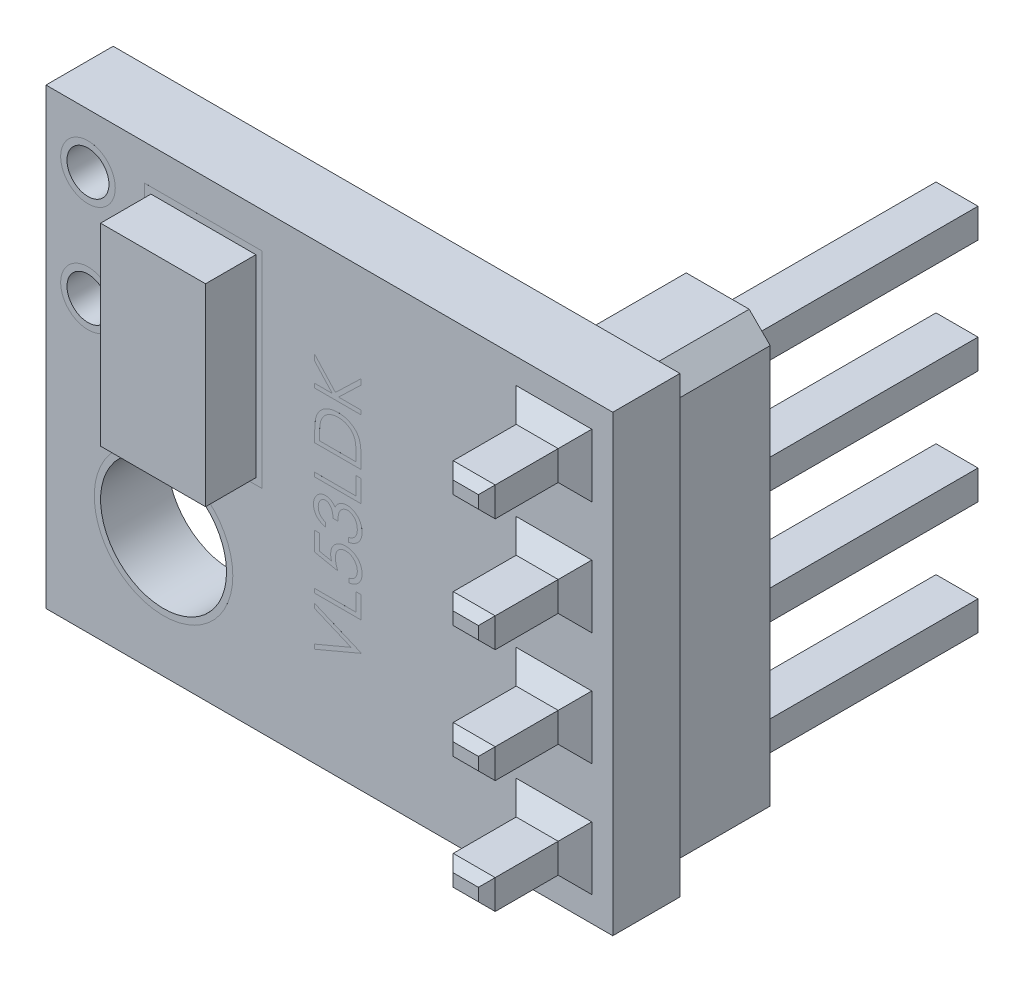
from build123d import *

# Parameters (mm, degrees)
SKETCH1_W                = 13.5
SKETCH1_H                = 10.8
BOSS_EXTRUDE1_DEPTH      = 0.8
SKETCH2_W                = 2.5
SKETCH2_H                = 4.6
BOSS_EXTRUDE2_DEPTH      = 1.2
SKETCH3_R                = 1.5
CUT_EXTRUDE1_DEPTH       = 3
CUT_EXTRUDE1_DEPTH_BACK  = 1.8
SKETCH6_R                = 0.5
CUT_EXTRUDE2_DEPTH       = 3
CUT_EXTRUDE2_DEPTH_BACK  = 1.8
SKETCH7_R                = 0.65
SKETCH7_R_2              = 0.5
SKETCH7_R_3              = 1.65
SKETCH7_R_4              = 1.5
BOSS_EXTRUDE6_DEPTH      = 0.0001
SKETCH8_W                = 2.8
SKETCH8_H                = 4.9
SKETCH8_W_2              = 2.5
SKETCH8_H_2              = 4.6
BOSS_EXTRUDE7_DEPTH      = 0.0001
SKETCH4_W                = 2.5
SKETCH4_H                = 10.5
BOSS_EXTRUDE3_DEPTH      = 2.3
SKETCH5_W                = 1
SKETCH5_H                = 0.7
BOSS_EXTRUDE4_DEPTH      = 5.9
BOSS_EXTRUDE4_DEPTH_BACK = 6
CHAMFER3_SIZE            = 0.2
CHAMFER1_SIZE            = 0.4
CHAMFER2_SIZE            = 0.5


with BuildPart() as part:
    # Sketch1 → Boss-Extrude1 (new body, symmetric)
    with BuildSketch(Plane.XY):
        Rectangle(SKETCH1_W, SKETCH1_H)
    extrude(amount=BOSS_EXTRUDE1_DEPTH, both=True)

    # Sketch2 → Boss-Extrude2 (add)
    with BuildSketch(Plane.XY.offset(0.8)):
        with Locations((-3, 2.1)):
            Rectangle(SKETCH2_W, SKETCH2_H)
    extrude(amount=BOSS_EXTRUDE2_DEPTH)

    # Sketch3 → Cut-Extrude1 (cut, two sides)
    with BuildSketch(Plane.XY) as cut_extrude1_sk:
        with Locations((-3.95, -2.5)):
            Circle(SKETCH3_R)
    extrude(amount=CUT_EXTRUDE1_DEPTH, mode=Mode.SUBTRACT)
    extrude(cut_extrude1_sk.sketch, amount=-CUT_EXTRUDE1_DEPTH_BACK, mode=Mode.SUBTRACT)

    # Sketch6 → Cut-Extrude2 (cut, two sides)
    with BuildSketch(Plane.XY) as cut_extrude2_sk:
        with Locations((-5.75, 4.1)):
            Circle(SKETCH6_R)
        with Locations((-5.75, 1.5)):
            Circle(SKETCH6_R)
    extrude(amount=CUT_EXTRUDE2_DEPTH, mode=Mode.SUBTRACT)
    extrude(cut_extrude2_sk.sketch, amount=-CUT_EXTRUDE2_DEPTH_BACK, mode=Mode.SUBTRACT)

    # Sketch7 → Boss-Extrude6 (add)
    with BuildSketch(Plane.XY.offset(0.8)):
        with Locations((-5.75, 1.5)):
            Circle(SKETCH7_R)
        with Locations((-5.75, 1.5)):
            Circle(SKETCH7_R_2, mode=Mode.SUBTRACT)
        with Locations((-5.75, 4.1)):
            Circle(SKETCH7_R)
        with Locations((-5.75, 4.1)):
            Circle(SKETCH7_R_2, mode=Mode.SUBTRACT)
        with Locations((-3.95, -2.5)):
            Circle(SKETCH7_R_3)
        with Locations((-3.95, -2.5)):
            Circle(SKETCH7_R_4, mode=Mode.SUBTRACT)
    boss_extrude6 = extrude(amount=BOSS_EXTRUDE6_DEPTH)

    # Sketch8 → Boss-Extrude7 (add)
    with BuildSketch(Plane.XY.offset(0.8)):
        with Locations((-3, 2.1)):
            Rectangle(SKETCH8_W, SKETCH8_H)
        with Locations((-3, 2.1)):
            Rectangle(SKETCH8_W_2, SKETCH8_H_2, mode=Mode.SUBTRACT)
        Polygon((-0.35, -3.039102564), (-0.35, -2.933333333), (0.516866987, -2.566666667), (-0.35, -2.2), (-0.35, -2.094230769), (0.75, -2.559615385), (0.75, -2.573717949), align=None)
        Polygon((-0.35, -1.882692308), (-0.35, -1.783974359), (0.637179487, -1.783974359), (0.637179487, -1.360897436), (0.75, -1.360897436), (0.75, -1.882692308), align=None)
        with BuildLine():
            Line((-0.35, -0.58525641), (-0.237179487, -0.58525641))
            Line((-0.237179487, -0.58525641), (-0.237179487, -0.959415064))
            Line((-0.237179487, -0.959415064), (0.052143429, -1.018689904))
            add(Edge.make_bspline(
                [(0.052143429, -1.018689904), (0.048928201, -1.007043772), (0.042699205, -0.984481233), (0.035783106, -0.951179563), (0.031613966, -0.91956487), (0.031044697, -0.899049754), (0.030769231, -0.889122596)],
                knots=[0, 0, 0, 0, 3.6238e-05, 7.0205e-05, 0.000101964, 0.000131741, 0.000131741, 0.000131741, 0.000131741], degree=3))
            add(Edge.make_bspline(
                [(0.030769231, -0.889122596), (0.031026316, -0.87683688), (0.03153181, -0.852680093), (0.03667389, -0.81739074), (0.044121774, -0.783533578), (0.055596649, -0.751608503), (0.069609518, -0.72111043), (0.087259033, -0.692563126), (0.107864798, -0.665565929), (0.13132069, -0.640305428), (0.157403456, -0.617496772), (0.185563621, -0.597676801), (0.215186682, -0.580377643), (0.246966944, -0.566885852), (0.280305019, -0.555875235), (0.315585743, -0.548614807), (0.3524959, -0.543765155), (0.377734772, -0.543224445), (0.390604968, -0.542948718)],
                knots=[0, 0, 0, 0, 3.6831e-05, 7.2419e-05, 0.000106789, 0.000140659, 0.000173979, 0.000207311, 0.000241115, 0.000275727, 0.000310552, 0.000344852, 0.000378907, 0.000413251, 0.000448232, 0.000484061, 0.000521149, 0.000559742, 0.000559742, 0.000559742, 0.000559742], degree=3))
            add(Edge.make_bspline(
                [(0.390604968, -0.542948718), (0.399569038, -0.54315793), (0.417376037, -0.543573526), (0.443822179, -0.545682322), (0.469704586, -0.549758102), (0.494975807, -0.555163854), (0.519659512, -0.562380264), (0.543893902, -0.570821168), (0.567413613, -0.581312654), (0.590322523, -0.592943637), (0.612358445, -0.605822759), (0.63299303, -0.620305045), (0.652697163, -0.635352975), (0.67088566, -0.651795617), (0.687629074, -0.669446026), (0.703010177, -0.688205995), (0.717305016, -0.707905366), (0.729929114, -0.728854405), (0.741546095, -0.750584832), (0.751076336, -0.773410861), (0.759596791, -0.796812791), (0.766388356, -0.821127467), (0.771710016, -0.846299808), (0.775324491, -0.872371309), (0.777957085, -0.899205234), (0.778121883, -0.917394524), (0.778205128, -0.926582532)],
                knots=[0, 0, 0, 0, 2.6897e-05, 5.3431e-05, 7.9516e-05, 0.000105448, 0.000130904, 0.000156621, 0.000182373, 0.000208094, 0.000233678, 0.000258861, 0.000283676, 0.000308015, 0.00033233, 0.000356594, 0.000380749, 0.000405276, 0.000429917, 0.000454597, 0.00047941, 0.000504593, 0.000530264, 0.000556534, 0.000583526, 0.000611078, 0.000611078, 0.000611078, 0.000611078], degree=3))
            add(Edge.make_bspline(
                [(0.778205128, -0.926582532), (0.777987424, -0.937542709), (0.777559116, -0.959105563), (0.773098773, -0.990701726), (0.766668289, -1.021083196), (0.757141178, -1.050119764), (0.744666105, -1.07769033), (0.729843832, -1.104189698), (0.712198142, -1.129289422), (0.691890434, -1.1528179), (0.669576543, -1.174445788), (0.645593481, -1.194058116), (0.619910704, -1.211300973), (0.592611726, -1.226236908), (0.563744968, -1.238960963), (0.533221484, -1.248961033), (0.501195525, -1.257031079), (0.479147313, -1.260445338), (0.467948718, -1.262179487)],
                knots=[0, 0, 0, 0, 3.2859e-05, 6.4646e-05, 9.555e-05, 0.000125932, 0.000156113, 0.000186206, 0.000216894, 0.000247989, 0.000279311, 0.000310009, 0.000340811, 0.000371973, 0.000403252, 0.000435305, 0.000468227, 0.000502207, 0.000502207, 0.000502207, 0.000502207], degree=3))
            Line((0.467948718, -1.262179487), (0.467948718, -1.163461538))
            add(Edge.make_bspline(
                [(0.467948718, -1.163461538), (0.478439552, -1.161034083), (0.498603518, -1.156368378), (0.526915977, -1.146100635), (0.552154748, -1.133668446), (0.574474144, -1.118540637), (0.594282718, -1.10100557), (0.611747892, -1.080621961), (0.627523714, -1.057899393), (0.640696215, -1.032636359), (0.651792271, -1.005932111), (0.659710781, -0.978141995), (0.664504026, -0.949665963), (0.665089981, -0.930493712), (0.665384615, -0.920853365)],
                knots=[0, 0, 0, 0, 3.228e-05, 6.2044e-05, 9.0129e-05, 0.00011647, 0.000142693, 0.000169247, 0.000196813, 0.000225498, 0.000254551, 0.000283427, 0.000312009, 0.000340916, 0.000340916, 0.000340916, 0.000340916], degree=3))
            add(Edge.make_bspline(
                [(0.665384615, -0.920853365), (0.665124498, -0.911438653), (0.664612325, -0.892901007), (0.66073388, -0.865605972), (0.654603728, -0.839330664), (0.646015737, -0.81402844), (0.634654327, -0.789823631), (0.620697491, -0.766750459), (0.604493438, -0.744480228), (0.585972796, -0.723599056), (0.565551447, -0.704479094), (0.543716297, -0.68758405), (0.520422273, -0.673511375), (0.49607361, -0.661652065), (0.470403195, -0.652646748), (0.4435314, -0.646222438), (0.415391834, -0.642450048), (0.396198622, -0.641931106), (0.386418269, -0.641666667)],
                knots=[0, 0, 0, 0, 2.8236e-05, 5.5597e-05, 8.2535e-05, 0.000109085, 0.000135602, 0.000162584, 0.000189866, 0.00021812, 0.000246182, 0.000273684, 0.00030078, 0.000327686, 0.000354796, 0.000382214, 0.000410448, 0.000439785, 0.000439785, 0.000439785, 0.000439785], degree=3))
            add(Edge.make_bspline(
                [(0.386418269, -0.641666667), (0.377593419, -0.641867329), (0.360392872, -0.642258442), (0.33513981, -0.645644274), (0.311207336, -0.651300255), (0.288491314, -0.659353222), (0.267064375, -0.669403582), (0.246973736, -0.682022114), (0.228030494, -0.696671509), (0.210722136, -0.713774347), (0.194722172, -0.732378693), (0.181132083, -0.752962404), (0.169574818, -0.77497597), (0.160105682, -0.798460186), (0.152562791, -0.823443979), (0.147349795, -0.849940805), (0.144230418, -0.877956703), (0.143807259, -0.897120477), (0.143589744, -0.906971154)],
                knots=[0, 0, 0, 0, 2.6465e-05, 5.1584e-05, 7.6276e-05, 0.000100111, 0.000123766, 0.000147124, 0.000171146, 0.000195455, 0.000220001, 0.000244631, 0.000269272, 0.000294478, 0.00032048, 0.000347446, 0.000375382, 0.000404929, 0.000404929, 0.000404929, 0.000404929], degree=3))
            add(Edge.make_bspline(
                [(0.143589744, -0.906971154), (0.143772215, -0.915497389), (0.144148972, -0.9331019), (0.146923014, -0.960106217), (0.151398221, -0.988483616), (0.157553899, -1.018125314), (0.16560938, -1.049120331), (0.175262509, -1.081403257), (0.186803709, -1.11504197), (0.195519547, -1.13770754), (0.2, -1.149358974)],
                knots=[0, 0, 0, 0, 2.5576e-05, 5.2808e-05, 8.1355e-05, 0.000111736, 0.000143589, 0.000177401, 0.0002128, 0.000250248, 0.000250248, 0.000250248, 0.000250248], degree=3))
            Line((0.2, -1.149358974), (-0.35, -1.036538462))
            Line((-0.35, -1.036538462), (-0.35, -0.58525641))
        make_face()
        with BuildLine():
            Line((-0.096153846, -0.289102564), (-0.096153846, -0.387820513))
            add(Edge.make_bspline(
                [(-0.096153846, -0.387820513), (-0.107226913, -0.385146083), (-0.128873852, -0.37991779), (-0.159801848, -0.369012839), (-0.18906924, -0.357133073), (-0.216128006, -0.342867926), (-0.241521947, -0.327308031), (-0.264675101, -0.30948089), (-0.286176318, -0.290208978), (-0.305257622, -0.268892565), (-0.322536336, -0.246537843), (-0.337268497, -0.222829819), (-0.349941803, -0.198245481), (-0.360382447, -0.172614497), (-0.368247611, -0.145860557), (-0.373954036, -0.118225533), (-0.377659815, -0.089637004), (-0.378021483, -0.070230618), (-0.378205128, -0.060376603)],
                knots=[0, 0, 0, 0, 3.4152e-05, 6.6764e-05, 9.8274e-05, 0.000128827, 0.000158421, 0.000187508, 0.000216368, 0.000244916, 0.000273211, 0.000301029, 0.000328525, 0.000356104, 0.000383922, 0.000412055, 0.000440699, 0.000470246, 0.000470246, 0.000470246, 0.000470246], degree=3))
            add(Edge.make_bspline(
                [(-0.378205128, -0.060376603), (-0.377771656, -0.046019169), (-0.376914166, -0.01761748), (-0.369083915, 0.024108049), (-0.356693159, 0.064345049), (-0.339572845, 0.102653098), (-0.318456832, 0.138236034), (-0.293325058, 0.169895979), (-0.26466242, 0.197203796), (-0.233003614, 0.220113458), (-0.199169025, 0.238051315), (-0.164346119, 0.251278461), (-0.128617499, 0.259330989), (-0.104493783, 0.260374593), (-0.092407853, 0.260897436)],
                knots=[0, 0, 0, 0, 4.3037e-05, 8.5135e-05, 0.000126884, 0.000169103, 0.00021071, 0.000250698, 0.000289974, 0.000329115, 0.00036756, 0.000404518, 0.000440608, 0.000476842, 0.000476842, 0.000476842, 0.000476842], degree=3))
            add(Edge.make_bspline(
                [(-0.092407853, 0.260897436), (-0.080777146, 0.260531736), (-0.058017657, 0.259816118), (-0.024790901, 0.25373981), (0.006525031, 0.243514128), (0.036061967, 0.229349345), (0.063632631, 0.211013429), (0.089299054, 0.18880201), (0.113175075, 0.162558316), (0.126852624, 0.14267065), (0.133894231, 0.132431891)],
                knots=[0, 0, 0, 0, 3.4872e-05, 6.8239e-05, 0.000100921, 0.000133444, 0.000166202, 0.00019995, 0.000235049, 0.000272295, 0.000272295, 0.000272295, 0.000272295], degree=3))
            add(Edge.make_bspline(
                [(0.133894231, 0.132431891), (0.13952403, 0.144148215), (0.150696368, 0.167399261), (0.172955169, 0.198771708), (0.198024105, 0.227685518), (0.217805987, 0.243620678), (0.227764423, 0.251642628)],
                knots=[0, 0, 0, 0, 3.8928e-05, 7.7253e-05, 0.000115023, 0.000153312, 0.000153312, 0.000153312, 0.000153312], degree=3))
            add(Edge.make_bspline(
                [(0.227764423, 0.251642628), (0.235011145, 0.256935622), (0.249385919, 0.267434932), (0.272497367, 0.280394671), (0.295864978, 0.292151821), (0.320115077, 0.301313319), (0.344966595, 0.308407962), (0.370462206, 0.313479287), (0.396622727, 0.316629731), (0.414320935, 0.317080905), (0.423217147, 0.317307692)],
                knots=[0, 0, 0, 0, 2.6897e-05, 5.3354e-05, 7.9371e-05, 0.000105317, 0.000130984, 0.000156826, 0.000183229, 0.000209914, 0.000209914, 0.000209914, 0.000209914], degree=3))
            add(Edge.make_bspline(
                [(0.423217147, 0.317307692), (0.438620124, 0.316743621), (0.46935359, 0.315618133), (0.514761112, 0.305560929), (0.559141665, 0.289963442), (0.601611537, 0.267838187), (0.641309643, 0.240751743), (0.677091108, 0.208883351), (0.707365284, 0.171777414), (0.732966609, 0.130778714), (0.753240829, 0.086169329), (0.76785375, 0.038650918), (0.776618568, -0.011501525), (0.777670254, -0.045798274), (0.778205128, -0.063241186)],
                knots=[0, 0, 0, 0, 4.6157e-05, 9.2097e-05, 0.000138862, 0.000186955, 0.000235301, 0.000282733, 0.00033016, 0.000378463, 0.000427374, 0.000476721, 0.000527257, 0.000579559, 0.000579559, 0.000579559, 0.000579559], degree=3))
            add(Edge.make_bspline(
                [(0.778205128, -0.063241186), (0.777929881, -0.075000797), (0.777388287, -0.098139791), (0.773751764, -0.132169719), (0.766929382, -0.164584042), (0.758349292, -0.195697517), (0.746486357, -0.225040566), (0.73234354, -0.253035261), (0.715558168, -0.279558892), (0.696102012, -0.304453942), (0.674323755, -0.327693816), (0.6498616, -0.348686439), (0.623172094, -0.36766407), (0.594015161, -0.384506129), (0.562472466, -0.399283498), (0.528417611, -0.411678166), (0.492114605, -0.422500242), (0.466822729, -0.427541614), (0.453846154, -0.430128205)],
                knots=[0, 0, 0, 0, 3.5281e-05, 6.9422e-05, 0.000102481, 0.000134565, 0.000166113, 0.000197254, 0.000228553, 0.000260113, 0.000291912, 0.000323939, 0.00035665, 0.000390023, 0.00042482, 0.000461005, 0.000498658, 0.000538334, 0.000538334, 0.000538334, 0.000538334], degree=3))
            Line((0.453846154, -0.430128205), (0.453846154, -0.331410256))
            add(Edge.make_bspline(
                [(0.453846154, -0.331410256), (0.462315844, -0.328838365), (0.478790126, -0.323835812), (0.502499937, -0.315320461), (0.524235325, -0.305619005), (0.544155735, -0.295211572), (0.562457347, -0.284281203), (0.57865622, -0.272050798), (0.593463855, -0.25942621), (0.601806447, -0.249909841), (0.605889423, -0.245252404)],
                knots=[0, 0, 0, 0, 2.6553e-05, 5.1648e-05, 7.5521e-05, 9.7894e-05, 0.000119057, 0.000139373, 0.000158734, 0.000177293, 0.000177293, 0.000177293, 0.000177293], degree=3))
            add(Edge.make_bspline(
                [(0.605889423, -0.245252404), (0.610635799, -0.239092792), (0.620113899, -0.226792581), (0.632243796, -0.206761461), (0.642626697, -0.185621153), (0.651066355, -0.16319536), (0.657401467, -0.139481075), (0.661961182, -0.114574493), (0.664971302, -0.088434748), (0.665244835, -0.070594883), (0.665384615, -0.061478365)],
                knots=[0, 0, 0, 0, 2.3314e-05, 4.6555e-05, 7.0108e-05, 9.3887e-05, 0.000118315, 0.000143642, 0.000169801, 0.000197138, 0.000197138, 0.000197138, 0.000197138], degree=3))
            add(Edge.make_bspline(
                [(0.665384615, -0.061478365), (0.665191045, -0.051184407), (0.664812535, -0.031055461), (0.661331599, -0.001683934), (0.65626204, 0.026258407), (0.648432246, 0.052461326), (0.638758264, 0.077268057), (0.626611622, 0.100330861), (0.612360424, 0.121952495), (0.596162403, 0.141856022), (0.578429933, 0.159753182), (0.559882968, 0.175511314), (0.540599707, 0.188907636), (0.52047344, 0.199713904), (0.499587511, 0.208246934), (0.477883308, 0.21405594), (0.455538453, 0.218094987), (0.440349348, 0.218423923), (0.432692308, 0.218589744)],
                knots=[0, 0, 0, 0, 3.0869e-05, 6.0362e-05, 8.8625e-05, 0.000115958, 0.000142269, 0.000168388, 0.000193995, 0.00021984, 0.000245238, 0.000269474, 0.000292762, 0.000315536, 0.000337877, 0.000360277, 0.000382845, 0.000405788, 0.000405788, 0.000405788, 0.000405788], degree=3))
            add(Edge.make_bspline(
                [(0.432692308, 0.218589744), (0.422443685, 0.21810778), (0.401997436, 0.21714625), (0.371904951, 0.209835855), (0.342900597, 0.19770305), (0.31536003, 0.181050544), (0.29014639, 0.160283607), (0.267488959, 0.136384076), (0.248810914, 0.10870176), (0.235894185, 0.083242464), (0.227082989, 0.060687109), (0.221213607, 0.04138527), (0.216243634, 0.019776009), (0.211619767, -0.003879116), (0.207684489, -0.029758416), (0.204402775, -0.057833696), (0.201776905, -0.08811065), (0.200604275, -0.10907073), (0.2, -0.119871795)],
                knots=[0, 0, 0, 0, 3.0725e-05, 6.1297e-05, 9.2316e-05, 0.00012474, 0.000157468, 0.000190052, 0.000223179, 0.000257276, 0.000275485, 0.000295768, 0.000317735, 0.000341979, 0.000368063, 0.000396243, 0.000426766, 0.000459219, 0.000459219, 0.000459219, 0.000459219], degree=3))
            Line((0.2, -0.119871795), (0.087179487, -0.119871795))
            add(Edge.make_bspline(
                [(0.087179487, -0.119871795), (0.086915262, -0.106267775), (0.08639789, -0.07963016), (0.08139606, -0.040616388), (0.073366156, -0.003468245), (0.061892809, 0.031280255), (0.048378592, 0.062891109), (0.032763287, 0.090426226), (0.015089284, 0.113160731), (-0.00430503, 0.13133214), (-0.024992613, 0.145143688), (-0.046686533, 0.155076553), (-0.069472793, 0.16099655), (-0.0850292, 0.161783786), (-0.092848558, 0.162179487)],
                knots=[0, 0, 0, 0, 4.0794e-05, 7.9878e-05, 0.000117785, 0.000154647, 0.000189483, 0.000220778, 0.000249343, 0.000275536, 0.000300165, 0.000323635, 0.00034683, 0.000370271, 0.000370271, 0.000370271, 0.000370271], degree=3))
            add(Edge.make_bspline(
                [(-0.092848558, 0.162179487), (-0.098593948, 0.162052094), (-0.110024129, 0.161798652), (-0.126775759, 0.158475381), (-0.143014557, 0.153711121), (-0.158555373, 0.146793988), (-0.173430013, 0.137831772), (-0.187801651, 0.127021578), (-0.201484585, 0.114055313), (-0.214549407, 0.099532955), (-0.22643478, 0.083451967), (-0.236836447, 0.066187463), (-0.245660272, 0.047809449), (-0.252960671, 0.028435648), (-0.258446228, 0.007975777), (-0.262386526, -0.013466498), (-0.26484966, -0.035934155), (-0.265204323, -0.0512624), (-0.265384615, -0.059054487)],
                knots=[0, 0, 0, 0, 1.721e-05, 3.4239e-05, 5.1039e-05, 6.7909e-05, 8.5103e-05, 0.00010304, 0.000121748, 0.000141566, 0.000161575, 0.000181641, 0.000201943, 0.000222653, 0.000243661, 0.0002654, 0.000288006, 0.00031138, 0.00031138, 0.00031138, 0.00031138], degree=3))
            add(Edge.make_bspline(
                [(-0.265384615, -0.059054487), (-0.26494733, -0.071579297), (-0.26409321, -0.096043164), (-0.256612263, -0.131310709), (-0.244676294, -0.164096786), (-0.230428774, -0.18915751), (-0.216364352, -0.207663461), (-0.204081316, -0.220887642), (-0.190431, -0.233874088), (-0.174572654, -0.245768444), (-0.157580234, -0.257797408), (-0.138589934, -0.268748556), (-0.118097124, -0.279390173), (-0.103609925, -0.285802403), (-0.096153846, -0.289102564)],
                knots=[0, 0, 0, 0, 3.7538e-05, 7.3321e-05, 0.000107622, 0.000141869, 0.000159321, 0.000177256, 0.000195964, 0.000215754, 0.000236659, 0.000258389, 0.00028145, 0.000305906, 0.000305906, 0.000305906, 0.000305906], degree=3))
        make_face()
        Polygon((-0.35, 0.51474359), (-0.35, 0.613461538), (0.637179487, 0.613461538), (0.637179487, 1.036538462), (0.75, 1.036538462), (0.75, 0.51474359), align=None)
        with BuildLine():
            Line((0.75, 1.219871795), (-0.35, 1.219871795))
            Line((-0.35, 1.219871795), (-0.35, 1.441987179))
            add(Edge.make_bspline(
                [(-0.35, 1.441987179), (-0.349860907, 1.461306004), (-0.349592179, 1.498629873), (-0.347888313, 1.552565214), (-0.344874167, 1.602468682), (-0.340483744, 1.648176152), (-0.335092791, 1.689813105), (-0.328335521, 1.727262953), (-0.320356381, 1.760719341), (-0.313553526, 1.781295451), (-0.310336538, 1.791025641)],
                knots=[0, 0, 0, 0, 5.7956e-05, 0.000111972, 0.000161867, 0.000207912, 0.000249702, 0.00028778, 0.000322038, 0.000352771, 0.000352771, 0.000352771, 0.000352771], degree=3))
            add(Edge.make_bspline(
                [(-0.310336538, 1.791025641), (-0.305488398, 1.803753705), (-0.295902058, 1.828921204), (-0.27779101, 1.864735374), (-0.257354692, 1.898565306), (-0.234122806, 1.930141277), (-0.208398723, 1.959542516), (-0.180366215, 1.987102717), (-0.149402551, 2.012142383), (-0.116058867, 2.035051507), (-0.08076239, 2.05571263), (-0.043570924, 2.073670288), (-0.004675919, 2.088584499), (0.03581516, 2.1009652), (0.077991155, 2.110722665), (0.12190123, 2.117379842), (0.167371832, 2.121770725), (0.198226663, 2.122211998), (0.213882212, 2.122435897)],
                knots=[0, 0, 0, 0, 4.0837e-05, 8.0747e-05, 0.000120201, 0.000159293, 0.000198181, 0.000237293, 0.000277076, 0.000317478, 0.000358558, 0.000399656, 0.000441232, 0.000483402, 0.000526592, 0.000570971, 0.000616556, 0.00066351, 0.00066351, 0.00066351, 0.00066351], degree=3))
            add(Edge.make_bspline(
                [(0.213882212, 2.122435897), (0.227478601, 2.122238222), (0.254271706, 2.121848681), (0.293758846, 2.118350898), (0.332074533, 2.113266904), (0.369036348, 2.1053959), (0.404967988, 2.095840719), (0.439487007, 2.083595229), (0.472908199, 2.069565513), (0.504786486, 2.05321219), (0.534968772, 2.035234543), (0.563442294, 2.016061922), (0.589575215, 1.995259507), (0.614052335, 1.973442985), (0.636219777, 1.950086256), (0.656481622, 1.925473683), (0.674498644, 1.899509615), (0.690553962, 1.872033328), (0.704911789, 1.842677869), (0.71688794, 1.81051986), (0.727260509, 1.775711626), (0.735511888, 1.738054666), (0.742166684, 1.697683291), (0.746597473, 1.654485508), (0.749602385, 1.608542957), (0.749864888, 1.576995079), (0.75, 1.560757212)],
                knots=[0, 0, 0, 0, 4.078e-05, 8.0361e-05, 0.000118848, 0.000156662, 0.000193652, 0.000230309, 0.000266447, 0.000302319, 0.000337691, 0.000371794, 0.00040521, 0.00043782, 0.000470083, 0.000501711, 0.000533374, 0.000564779, 0.000597105, 0.000631277, 0.0006676, 0.000705985, 0.000746848, 0.000790284, 0.000836207, 0.000884912, 0.000884912, 0.000884912, 0.000884912], degree=3))
            Line((0.75, 1.560757212), (0.75, 1.219871795))
        make_face()
        with BuildLine():
            Line((0.637179487, 1.318589744), (0.637179487, 1.444851763))
            add(Edge.make_bspline(
                [(0.637179487, 1.444851763), (0.637101514, 1.462994965), (0.636951543, 1.497890987), (0.635635565, 1.548069215), (0.633485242, 1.593917025), (0.630475932, 1.635440928), (0.626494367, 1.672617479), (0.622055112, 1.705524372), (0.616524484, 1.734053739), (0.611511326, 1.751317276), (0.609194712, 1.759294872)],
                knots=[0, 0, 0, 0, 5.4429e-05, 0.000104687, 0.000150573, 0.000192114, 0.000229564, 0.000262721, 0.000291718, 0.00031663, 0.00031663, 0.00031663, 0.00031663], degree=3))
            add(Edge.make_bspline(
                [(0.609194712, 1.759294872), (0.605658508, 1.769335787), (0.598670564, 1.789177789), (0.585923861, 1.817740401), (0.570824959, 1.844378372), (0.554041259, 1.869555605), (0.534981567, 1.892916171), (0.514057454, 1.914732327), (0.491173323, 1.934977366), (0.466366282, 1.953339457), (0.439905334, 1.969971286), (0.411743679, 1.984249014), (0.382277228, 1.996683044), (0.351267434, 2.006528545), (0.318941582, 2.01429129), (0.285132049, 2.019732541), (0.249868751, 2.023110552), (0.225862414, 2.023513276), (0.213661859, 2.023717949)],
                knots=[0, 0, 0, 0, 3.1929e-05, 6.3096e-05, 9.368e-05, 0.000123688, 0.000153766, 0.000184, 0.000214285, 0.000245311, 0.000276493, 0.00030793, 0.000339932, 0.000372336, 0.000405419, 0.00043958, 0.000474991, 0.000511586, 0.000511586, 0.000511586, 0.000511586], degree=3))
            add(Edge.make_bspline(
                [(0.213661859, 2.023717949), (0.200797051, 2.02355663), (0.175524022, 2.023239717), (0.138441232, 2.019256363), (0.102775884, 2.013435302), (0.068525594, 2.005017573), (0.035623541, 1.994290725), (0.004251695, 1.980903837), (-0.025921264, 1.965608614), (-0.054198922, 1.947410423), (-0.080942471, 1.927479808), (-0.105442587, 1.905361046), (-0.127755081, 1.881405548), (-0.148227437, 1.855874595), (-0.16603602, 1.82804865), (-0.18196612, 1.798583204), (-0.1954854, 1.767045993), (-0.2026759, 1.74510486), (-0.206330128, 1.733954327)],
                knots=[0, 0, 0, 0, 3.8577e-05, 7.5786e-05, 0.000111758, 0.000146924, 0.000181486, 0.000215455, 0.00024916, 0.000282842, 0.000316203, 0.000349124, 0.000381707, 0.000414332, 0.000447153, 0.000480673, 0.000514728, 0.000549919, 0.000549919, 0.000549919, 0.000549919], degree=3))
            add(Edge.make_bspline(
                [(-0.206330128, 1.733954327), (-0.208881006, 1.724729681), (-0.214304871, 1.705115553), (-0.220221416, 1.673108864), (-0.225439973, 1.63708696), (-0.229858214, 1.596889911), (-0.233028515, 1.552563538), (-0.235408071, 1.50407375), (-0.237013013, 1.451399589), (-0.237122606, 1.414885078), (-0.237179487, 1.395933494)],
                knots=[0, 0, 0, 0, 2.8701e-05, 6.1026e-05, 9.7549e-05, 0.000137894, 0.000182308, 0.000230846, 0.000283533, 0.000340386, 0.000340386, 0.000340386, 0.000340386], degree=3))
            Line((-0.237179487, 1.395933494), (-0.237179487, 1.318589744))
            Line((-0.237179487, 1.318589744), (0.637179487, 1.318589744))
        make_face(mode=Mode.SUBTRACT)
        Polygon((-0.35, 2.348076923), (-0.35, 2.446794872), (0.068890224, 2.446794872), (-0.35, 2.905348558), (-0.35, 3.046153846), (0.143589744, 2.505629006), (0.75, 3.088461538), (0.75, 2.956911058), (0.219170673, 2.446794872), (0.75, 2.446794872), (0.75, 2.348076923), align=None)
    extrude(amount=BOSS_EXTRUDE7_DEPTH)

    # Mirror1: Boss-Extrude6 across plane
    add(boss_extrude6.mirror(Plane.XY))

    # Sketch4 → Boss-Extrude3 (add)
    with BuildSketch(Plane(origin=(0, 0, -0.8), x_dir=(-1, 0, 0), z_dir=(0, 0, -1))):
        with Locations((-5.35, 0)):
            Rectangle(SKETCH4_W, SKETCH4_H)
    extrude(amount=BOSS_EXTRUDE3_DEPTH)

    # Sketch5 → Boss-Extrude4 (add, two sides)
    with BuildSketch(Plane(origin=(0, 0, -3.1), x_dir=(-1, 0, 0), z_dir=(0, 0, -1))) as boss_extrude4_sk:
        with Locations((-5.35, 1.35)):
            Rectangle(SKETCH5_W, SKETCH5_H)
        with Locations((-5.35, 4.05)):
            Rectangle(SKETCH5_W, SKETCH5_H)
        with Locations((-5.35, -1.35)):
            Rectangle(SKETCH5_W, SKETCH5_H)
        with Locations((-5.35, -4.05)):
            Rectangle(SKETCH5_W, SKETCH5_H)
    extrude(amount=BOSS_EXTRUDE4_DEPTH)
    extrude(boss_extrude4_sk.sketch, amount=-BOSS_EXTRUDE4_DEPTH_BACK)

    # Chamfer3
    chamfer3_edges = [part.edges().sort_by_distance(p)[0] for p in [
        (5.85, 4.05, 2.9),
        (5.35, 4.4, 2.9),
        (4.85, 4.05, 2.9),
        (5.35, 3.7, 2.9),
        (5.85, 4.05, -9),
        (5.35, 3.7, -9),
        (4.85, 4.05, -9),
        (5.35, 4.4, -9),
        (5.85, -4.05, 2.9),
        (5.35, -3.7, 2.9),
        (4.85, -4.05, 2.9),
        (5.35, -4.4, 2.9),
        (5.85, -4.05, -9),
        (5.35, -4.4, -9),
        (4.85, -4.05, -9),
        (5.35, -3.7, -9),
        (5.85, 1.35, 2.9),
        (5.35, 1.7, 2.9),
        (4.85, 1.35, 2.9),
        (5.35, 1, 2.9),
        (5.85, 1.35, -9),
        (5.35, 1, -9),
        (4.85, 1.35, -9),
        (5.35, 1.7, -9),
        (5.85, -1.35, 2.9),
        (5.35, -1, 2.9),
        (4.85, -1.35, 2.9),
        (5.35, -1.7, 2.9),
        (5.85, -1.35, -9),
        (5.35, -1.7, -9),
        (4.85, -1.35, -9),
        (5.35, -1, -9),
    ]]
    chamfer(chamfer3_edges, length=CHAMFER3_SIZE)

    # Chamfer1
    chamfer1_edges = [part.edges().sort_by_distance(p)[0] for p in [
        (5.85, 4.05, 0.8),
        (5.35, 4.4, 0.8),
        (4.85, 4.05, 0.8),
        (5.35, 3.7, 0.8),
        (5.85, -4.05, 0.8),
        (5.35, -3.7, 0.8),
        (4.85, -4.05, 0.8),
        (5.35, -4.4, 0.8),
        (5.85, 1.35, 0.8),
        (5.35, 1.7, 0.8),
        (4.85, 1.35, 0.8),
        (5.35, 1, 0.8),
        (5.85, -1.35, 0.8),
        (5.35, -1, 0.8),
        (4.85, -1.35, 0.8),
        (5.35, -1.7, 0.8),
    ]]
    chamfer(chamfer1_edges, length=CHAMFER1_SIZE)

    # Chamfer2
    chamfer2_edges = [part.edges().sort_by_distance(p)[0] for p in [
        (4.1, -5.25, -1.95),
        (4.1, 5.25, -1.95),
        (6.6, 5.25, -1.95),
        (6.6, -5.25, -1.95),
    ]]
    chamfer(chamfer2_edges, length=CHAMFER2_SIZE)


solid = part.part
